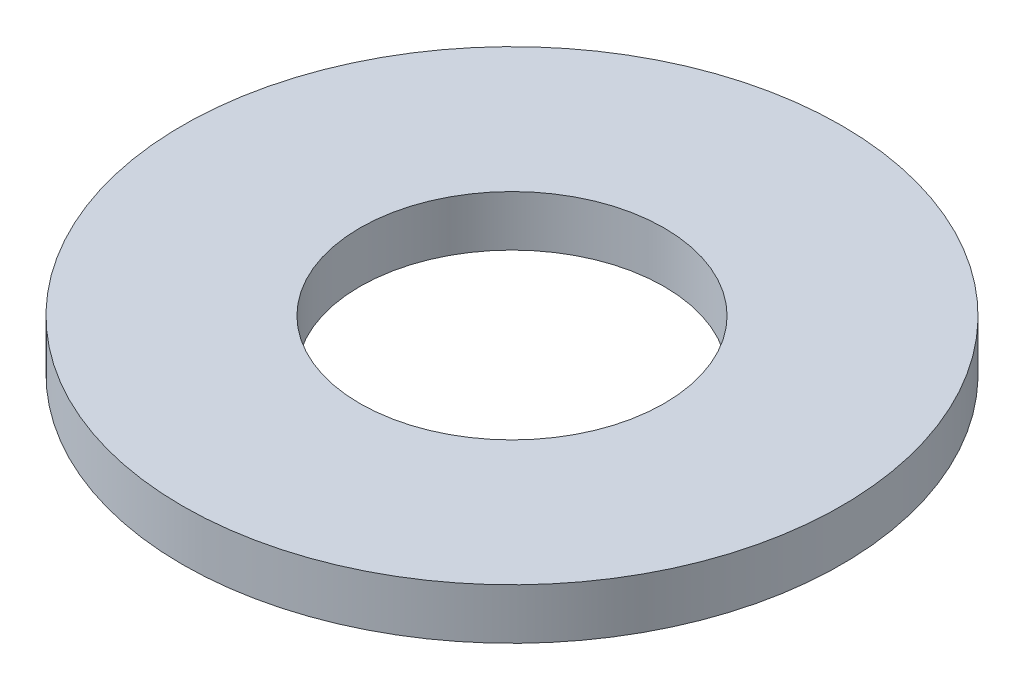
from build123d import *

# Parameters (mm, degrees)
SKETCH1_W = 7
SKETCH1_H = 2


with BuildPart() as part:
    # Sketch1 → Revolve1 (revolve)
    with BuildSketch(Plane(origin=(0, 0, 0), x_dir=(-1, 0, 0), z_dir=(0, 0, -1))):
        with Locations((-9.5, 1)):
            Rectangle(SKETCH1_W, SKETCH1_H)
    revolve(axis=Axis((0, 0, 0), (0, 1, 0)))


solid = part.part
